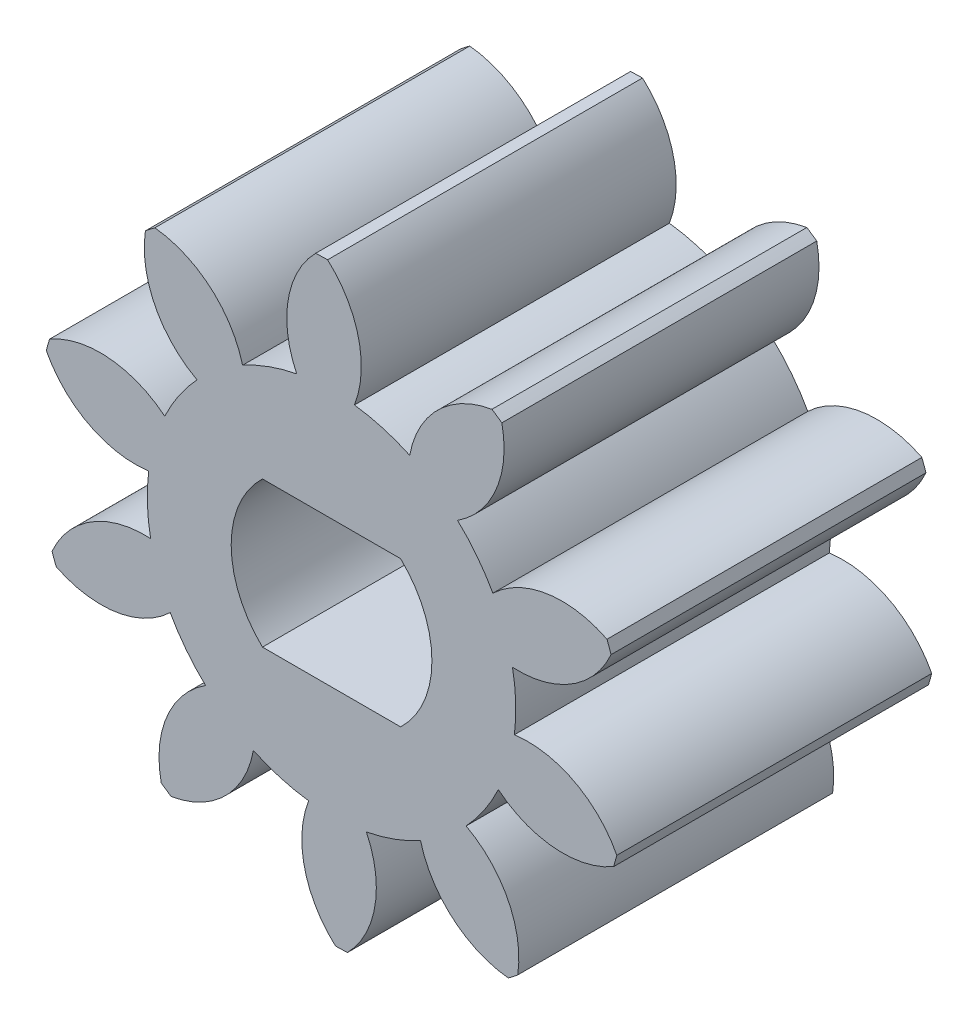
from build123d import *

# Parameters (mm, degrees)
SKIZZE1_R                       = 7.5
AUFSATZ_LINEAR_AUSTRAGEN1_DEPTH = 8
SCHNITT_LINEAR_AUSTRAGEN1_DEPTH = 14.285330256
KREISMUSTER1_COUNT              = 10
SCHNITT_LINEAR_AUSTRAGEN3_REACH = 15.144


with BuildPart() as part:
    # Skizze1 → Aufsatz-Linear austragen1 (new body)
    with BuildSketch(Plane.XY):
        Circle(SKIZZE1_R)
    extrude(amount=AUFSATZ_LINEAR_AUSTRAGEN1_DEPTH)

    # Skizze3 → Schnitt-Linear austragen1 (cut, through all)
    with BuildSketch(Plane.XY.offset(8)):
        with BuildLine():
            ThreePointArc((1.98549644, 4.239169305), (1.299374701, 4.497152198), (0.581391256, 4.644861324))
            ThreePointArc((0.581391256, 4.644861324), (0.684746364, 6.178122942), (-0.100097626, 7.499332001))
            ThreePointArc((-0.100097626, 7.499332001), (2.076040858, 7.20694487), (4.074246256, 6.296865684))
            ThreePointArc((4.074246256, 6.296865684), (2.704090414, 5.598714906), (1.98549644, 4.239169305))
        make_face()
    schnitt_linear_austragen1 = extrude(amount=-SCHNITT_LINEAR_AUSTRAGEN1_DEPTH, mode=Mode.SUBTRACT)

    # Kreismuster1: Schnitt-Linear austragen1 ×10 about axis
    kreismuster1_axis = Axis((0, 0, 8), (0, 0, -1))
    for i in range(1, KREISMUSTER1_COUNT):
        add(schnitt_linear_austragen1.rotate(kreismuster1_axis, i * 360 / KREISMUSTER1_COUNT), mode=Mode.SUBTRACT)

    # Skizze4 → Schnitt-Linear austragen3 (cut, up to next)
    with BuildSketch(Plane.XY.offset(8), mode=Mode.PRIVATE) as schnitt_linear_austragen3_sk1:
        with BuildLine():
            Line((1.754992877, -1.85), (-1.754992877, -1.85))
            ThreePointArc((-1.754992877, -1.85), (-2.55, 0), (-1.754992877, 1.85))
            Line((-1.754992877, 1.85), (1.754992877, 1.85))
            ThreePointArc((1.754992877, 1.85), (2.55, 0), (1.754992877, -1.85))
        make_face()
    schnitt_linear_austragen3_tool1 = extrude(schnitt_linear_austragen3_sk1.sketch, amount=-SCHNITT_LINEAR_AUSTRAGEN3_REACH, mode=Mode.PRIVATE) & part.part
    add(schnitt_linear_austragen3_tool1.solids().sort_by_distance((0, 0, 8))[0], mode=Mode.SUBTRACT)


solid = part.part
